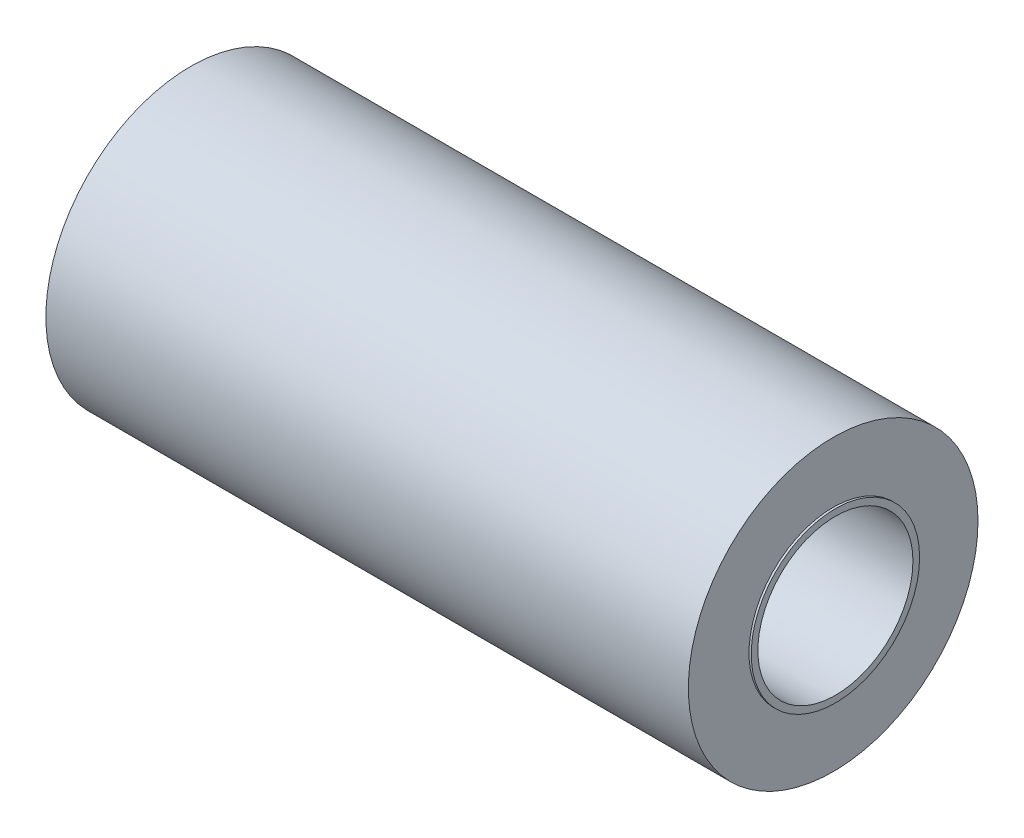
from build123d import *

# Parameters (mm, degrees)
SALIENTE_EXTRUIR1_DEPTH      = 146
SALIENTE_EXTRUIR1_DEPTH_BACK = 146
CROQUIS1_R                   = 38
CROQUIS1_R_2                 = 35
SALIENTE_EXTRUIR2_DEPTH      = 145
SALIENTE_EXTRUIR2_DEPTH_BACK = 145
CROQUIS2_R                   = 65.363922799
CROQUIS2_R_2                 = 38


with BuildPart() as part:
    # Croquis1 → Saliente-Extruir1 (new, two sides: drawn at the far end of the back side and taken through both)
    with BuildSketch(Plane(origin=(0, 0, 0), x_dir=(0, 0, -1), z_dir=(1, 0, 0)).offset(-SALIENTE_EXTRUIR1_DEPTH_BACK)):
        Circle(CROQUIS1_R)
        Circle(CROQUIS1_R_2, mode=Mode.SUBTRACT)
    extrude(amount=SALIENTE_EXTRUIR1_DEPTH + SALIENTE_EXTRUIR1_DEPTH_BACK)

    # Croquis2 → Saliente-Extruir2 (add, two sides: drawn at the far end of the back side and taken through both)
    with BuildSketch(Plane(origin=(0, 0, 0), x_dir=(0, 0, -1), z_dir=(1, 0, 0)).offset(-SALIENTE_EXTRUIR2_DEPTH_BACK)):
        Circle(CROQUIS2_R)
        Circle(CROQUIS2_R_2, mode=Mode.SUBTRACT)
    extrude(amount=SALIENTE_EXTRUIR2_DEPTH + SALIENTE_EXTRUIR2_DEPTH_BACK)


solid = part.part
